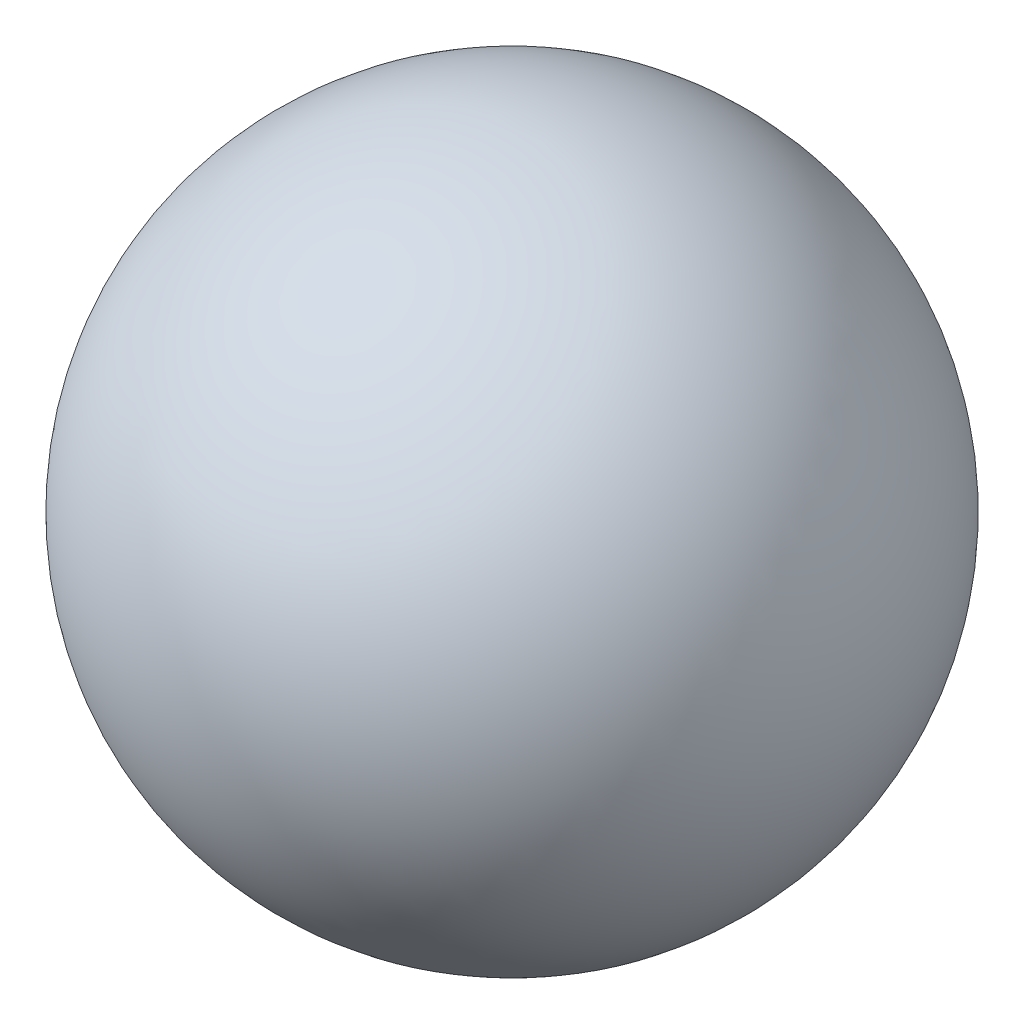
from build123d import *


with BuildPart() as part:
    # Croquis1 → Revolución3 (revolve)
    with BuildSketch(Plane.XY):
        with BuildLine():
            Line((0, 7.5), (0, -7.5))
            ThreePointArc((0, -7.5), (-7.5, 0), (0, 7.5))
        make_face()
    revolve(axis=Axis((0, 7.5, 0), (0, -1, 0)))


solid = part.part
